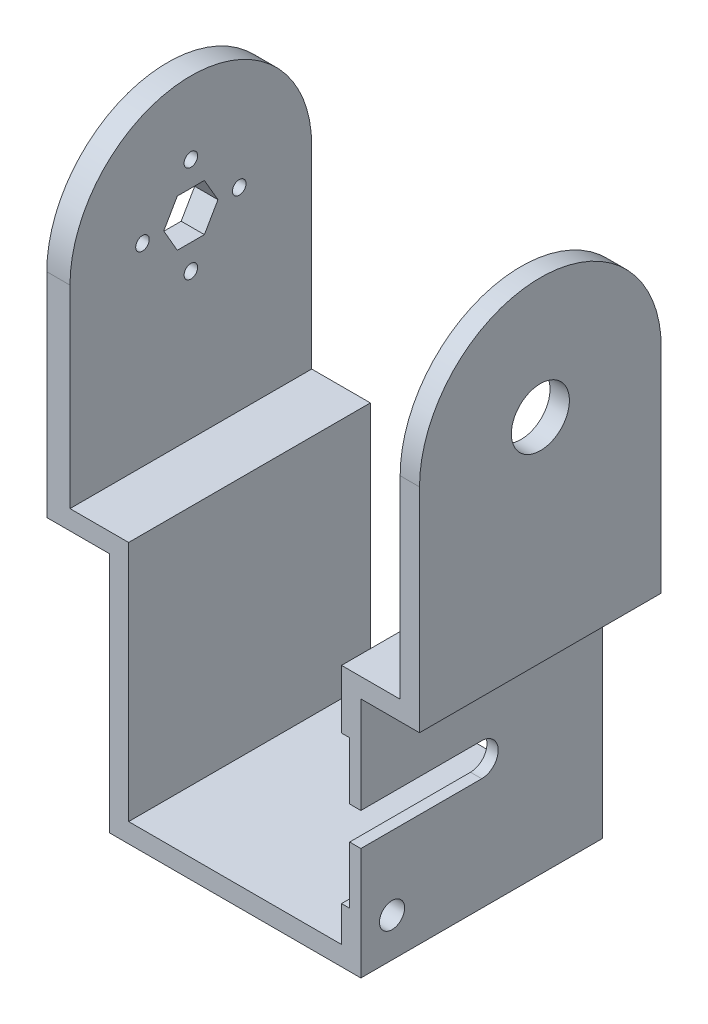
from build123d import *

# Parameters (mm, degrees)
BOSS_EXTRUDE1_DEPTH = 5
SKETCH2_W           = 5
SKETCH2_H           = 62.45
BOSS_EXTRUDE2_DEPTH = 67.45
SKETCH6_R           = 3.25
CUT_EXTRUDE4_DEPTH  = 5
CUT_EXTRUDE5_DEPTH  = 2.1
CUT_EXTRUDE6_DEPTH  = 5
SKETCH8_W           = 15.15
SKETCH8_H           = 5
BOSS_EXTRUDE3_DEPTH = 62.45
SKETCH9_W           = 62.45
SKETCH9_H           = 55
BOSS_EXTRUDE4_DEPTH = 6
SKETCH10_W          = 62.45
SKETCH10_H          = 55
BOSS_EXTRUDE5_DEPTH = 5
BOSS_EXTRUDE6_DEPTH = 6
CUT_EXTRUDE7_DEPTH  = 6
BOSS_EXTRUDE7_DEPTH = 5
SKETCH14_R          = 7.5
CUT_EXTRUDE8_DEPTH  = 5
SKETCH12_3_R        = 1.75
CUT_EXTRUDE9_DEPTH  = 6
SKETCH16_R          = 3
BOSS_EXTRUDE8_DEPTH = 17


with BuildPart() as part:
    # Sketch1 → Boss-Extrude1 (new body)
    with BuildSketch(Plane(origin=(0, 0, 0), x_dir=(1, 0, 0), z_dir=(0, 1, 0))):
        Polygon((-27.5, 0), (-27.5, 31.225), (27.5, 31.225), (27.5, -31.225), (-27.5, -31.225), align=None)
    extrude(amount=-BOSS_EXTRUDE1_DEPTH)

    # Sketch2 → Boss-Extrude2 (add)
    with BuildSketch(Plane.XZ.offset(5)):
        with Locations((30, 0)):
            Rectangle(SKETCH2_W, SKETCH2_H)
        with Locations((-30, 0)):
            Rectangle(SKETCH2_W, SKETCH2_H)
    extrude(amount=-BOSS_EXTRUDE2_DEPTH)

    # Sketch6 → Cut-Extrude4 (cut)
    with BuildSketch(Plane.ZY.offset(-27.5)):
        with Locations((-23.175, 51.4)):
            Circle(SKETCH6_R)
        with Locations((23.175, 5.05)):
            Circle(SKETCH6_R)
    extrude(amount=-CUT_EXTRUDE4_DEPTH, mode=Mode.SUBTRACT)

    # Sketch7 → Cut-Extrude5 (cut)
    with BuildSketch(Plane.ZY.offset(-27.5)):
        with BuildLine():
            Line((0, 47.3), (31.225, 47.3))
            Line((31.225, 47.3), (31.225, 9.15))
            Line((31.225, 9.15), (0, 9.15))
            ThreePointArc((0, 9.15), (-19.075, 28.225), (0, 47.3))
        make_face()
    extrude(amount=-CUT_EXTRUDE5_DEPTH, mode=Mode.SUBTRACT)

    # Sketch7_3 → Cut-Extrude6 (cut)
    with BuildSketch(Plane.ZY.offset(-27.5)):
        with BuildLine():
            Line((0, 32.475), (31.225, 32.475))
            Line((31.225, 32.475), (31.225, 23.975))
            Line((31.225, 23.975), (0, 23.975))
            ThreePointArc((0, 23.975), (-4.25, 28.225), (0, 32.475))
        make_face()
    extrude(amount=-CUT_EXTRUDE6_DEPTH, mode=Mode.SUBTRACT)

    # Sketch8 → Boss-Extrude3 (add)
    with BuildSketch(Plane(origin=(0, 0, -31.225), x_dir=(-1, 0, 0), z_dir=(0, 0, -1))):
        with Locations((35.075, 59.95)):
            Rectangle(SKETCH8_W, SKETCH8_H)
        with Locations((-35.075, 59.95)):
            Rectangle(SKETCH8_W, SKETCH8_H)
    extrude(amount=-BOSS_EXTRUDE3_DEPTH)

    # Sketch9 → Boss-Extrude4 (add)
    with BuildSketch(Plane.ZY.offset(42.65)):
        with Locations((0, 84.95)):
            Rectangle(SKETCH9_W, SKETCH9_H)
    extrude(amount=BOSS_EXTRUDE4_DEPTH)

    # Sketch10 → Boss-Extrude5 (add)
    with BuildSketch(Plane(origin=(42.65, 0, 0), x_dir=(0, 0, -1), z_dir=(1, 0, 0))):
        with Locations((0, 84.95)):
            Rectangle(SKETCH10_W, SKETCH10_H)
    extrude(amount=BOSS_EXTRUDE5_DEPTH)

    # Sketch11 → Boss-Extrude6 (add)
    with BuildSketch(Plane(origin=(-42.65, 0, 0), x_dir=(0, 0, -1), z_dir=(1, 0, 0))):
        with BuildLine():
            Line((-31.225, 112.45), (31.225, 112.45))
            ThreePointArc((31.225, 112.45), (0, 143.675), (-31.225, 112.45))
        make_face()
    extrude(amount=-BOSS_EXTRUDE6_DEPTH)

    # Sketch12 → Cut-Extrude7 (cut)
    with BuildSketch(Plane(origin=(-42.65, 0, 0), x_dir=(0, 0, -1), z_dir=(1, 0, 0))):
        Polygon((7, 112.45), (3.5, 118.512177826), (-3.5, 118.512177826), (-7, 112.45), (-3.5, 106.387822174), (3.5, 106.387822174), align=None)
    extrude(amount=-CUT_EXTRUDE7_DEPTH, mode=Mode.SUBTRACT)

    # Sketch13 → Boss-Extrude7 (add)
    with BuildSketch(Plane.ZY.offset(-42.65)):
        with BuildLine():
            Line((-31.225, 112.45), (31.225, 112.45))
            ThreePointArc((31.225, 112.45), (0, 143.675), (-31.225, 112.45))
        make_face()
    extrude(amount=-BOSS_EXTRUDE7_DEPTH)

    # Sketch14 → Cut-Extrude8 (cut)
    with BuildSketch(Plane.ZY.offset(-42.65)):
        with Locations((0, 112.45)):
            Circle(SKETCH14_R)
    extrude(amount=-CUT_EXTRUDE8_DEPTH, mode=Mode.SUBTRACT)

    # Sketch12_3 → Cut-Extrude9 (cut)
    with BuildSketch(Plane(origin=(-42.65, 0, 0), x_dir=(0, 0, -1), z_dir=(1, 0, 0))):
        with Locations((0, 124.95)):
            Circle(SKETCH12_3_R)
        with Locations((-12.5, 112.45)):
            Circle(SKETCH12_3_R)
        with Locations((0, 99.95)):
            Circle(SKETCH12_3_R)
        with Locations((12.5, 112.45)):
            Circle(SKETCH12_3_R)
    extrude(amount=-CUT_EXTRUDE9_DEPTH, mode=Mode.SUBTRACT)

    # Sketch16 → Boss-Extrude8 (add)
    with BuildSketch(Plane(origin=(-27.5, 0, 0), x_dir=(0, 0, -1), z_dir=(1, 0, 0))):
        with Locations((0, 28.22)):
            Circle(SKETCH16_R)
    extrude(amount=-BOSS_EXTRUDE8_DEPTH)


solid = part.part
